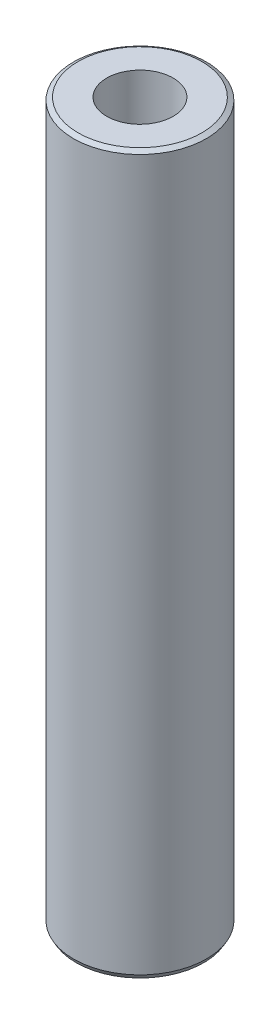
from build123d import *

# Parameters (mm, degrees)
SKETCH2_R             = 2.5
BOSS_EXTRUDE1_DEPTH   = 27
CHAMFER1_SIZE         = 0.1
CHAMFER1_SIZE2        = 0.173205081
CHAMFER1_PART_2_SIZE  = 0.1
CHAMFER1_PART_2_SIZE2 = 0.173205081
M3X0_5_TAPPED_HOLE1_D = 2.5


with BuildPart() as part:
    # Sketch2 → Boss-Extrude1 (new body)
    with BuildSketch(Plane(origin=(0, 0, 0), x_dir=(1, 0, 0), z_dir=(0, 1, 0))):
        Circle(SKETCH2_R)
    extrude(amount=BOSS_EXTRUDE1_DEPTH)

    # Chamfer1
    chamfer1_edges = [part.edges().sort_by_distance(p)[0] for p in [
        (-2.5, 0, 0),
    ]]
    chamfer1_side = [part.faces().sort_by_distance(p)[0] for p in [
        (0, 0, 0),
    ]]
    chamfer(chamfer1_edges, length=CHAMFER1_SIZE, length2=CHAMFER1_SIZE2, reference=chamfer1_side[0])

    # Chamfer1 part 2
    chamfer1_part_2_edges = [part.edges().sort_by_distance(p)[0] for p in [
        (-2.5, 27, 0),
    ]]
    chamfer1_part_2_side = [part.faces().sort_by_distance(p)[0] for p in [
        (-2.5, 13.5, 0),
    ]]
    chamfer(chamfer1_part_2_edges, length=CHAMFER1_PART_2_SIZE, length2=CHAMFER1_PART_2_SIZE2, reference=chamfer1_part_2_side[0])

    # M3x0.5 Tapped Hole1 (through all)
    with Locations(Plane(origin=(0, 27, 0), x_dir=(1, 0, 0), z_dir=(0, 1, 0))):
        with Locations((0, 0)):
            Hole(M3X0_5_TAPPED_HOLE1_D / 2)


solid = part.part
